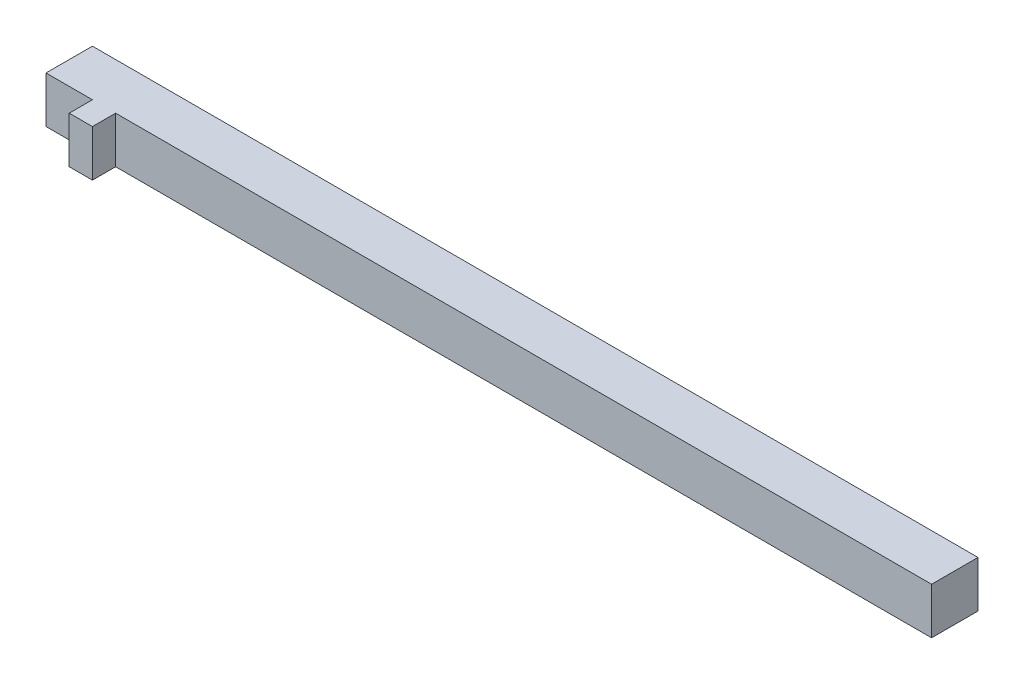
from build123d import *

# Parameters (mm, degrees)
CROQUIS1_W              = 3815
CROQUIS1_H              = 200
SALIENTE_EXTRUIR1_DEPTH = 200
CROQUIS3_W              = 100
CROQUIS3_H              = 200
SALIENTE_EXTRUIR6_DEPTH = 100


with BuildPart() as part:
    # Croquis1 → Saliente-Extruir1 (new body)
    with BuildSketch(Plane.XY):
        Rectangle(CROQUIS1_W, CROQUIS1_H)
    extrude(amount=SALIENTE_EXTRUIR1_DEPTH)

    # Croquis3 → Saliente-Extruir6 (add)
    with BuildSketch(Plane.XY.offset(200)):
        with Locations((-1657.5, 0)):
            Rectangle(CROQUIS3_W, CROQUIS3_H)
    extrude(amount=SALIENTE_EXTRUIR6_DEPTH)


solid = part.part
